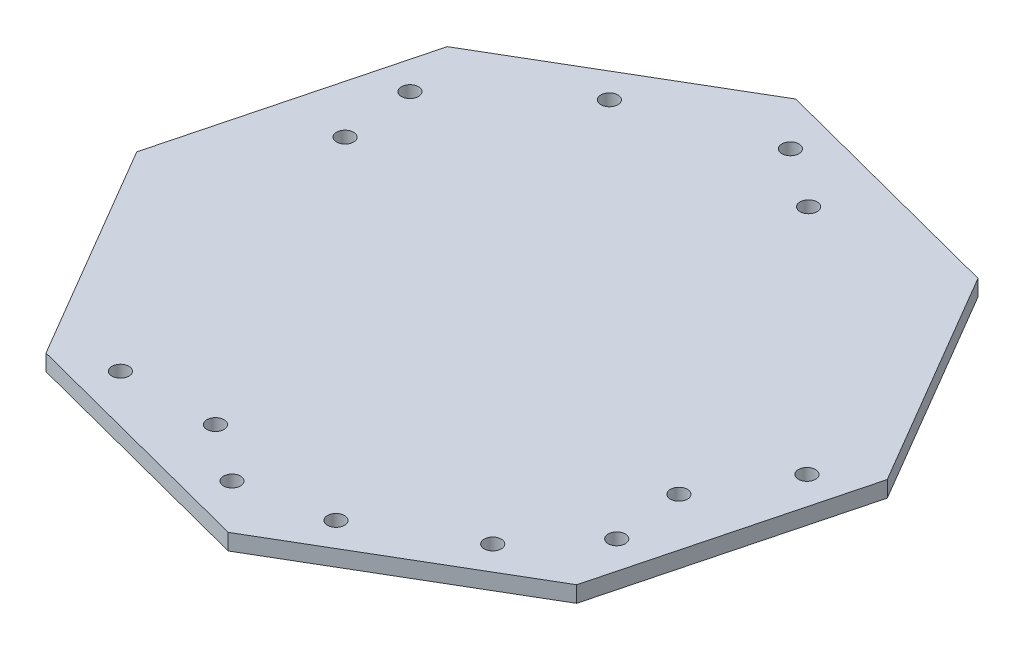
from build123d import *

# Parameters (mm, degrees)
BOSS_EXTRUDE1_DEPTH = 3
SKETCH2_R           = 1.5875
CUT_EXTRUDE1_DEPTH  = 3
SKETCH3_R           = 1.5875
CUT_EXTRUDE2_DEPTH  = 3


with BuildPart() as part:
    # Sketch1 → Boss-Extrude1 (new body)
    with BuildSketch(Plane(origin=(-113.226454214, -170.109741769, -309.439751514), x_dir=(0.890793361, 0, -0.454408614), z_dir=(0, -1, 0))):
        Polygon((16.200077076, -64.648683729), (51.592412285, -33.201987218), (54.382400165, 14.060345359), (22.935703655, 49.452680569), (-24.326628923, 52.242668449), (-59.718964132, 20.795971938), (-62.508952012, -26.466360639), (-31.062255502, -61.858695849), align=None)
    extrude(amount=BOSS_EXTRUDE1_DEPTH)

    # Sketch2 → Cut-Extrude1 (cut)
    with BuildSketch(Plane.XZ.offset(173.109741769)):
        with Locations((-145.375224309, -356.932300191)):
            Circle(SKETCH2_R)
        with Locations((-120.656222706, -365.870996639)):
            Circle(SKETCH2_R)
        with Locations((-165.234257313, -339.711726955)):
            Circle(SKETCH2_R)
        with Locations((-147.129073232, -267.776351499)):
            Circle(SKETCH2_R)
        with Locations((-119.068249233, -260.469800508)):
            Circle(SKETCH2_R)
        with Locations((-103.064133068, -263.787192741)):
            Circle(SKETCH2_R)
        with Locations((-84.693579832, -274.567395605)):
            Circle(SKETCH2_R)
        with Locations((-73.99225652, -286.921281828)):
            Circle(SKETCH2_R)
        with Locations((-66.685705529, -314.982105827)):
            Circle(SKETCH2_R)
    extrude(amount=-CUT_EXTRUDE1_DEPTH, mode=Mode.SUBTRACT)

    # Sketch3 → Cut-Extrude2 (cut)
    with BuildSketch(Plane(origin=(0, -170.109741769, 0), x_dir=(1, 0, 0), z_dir=(0, 1, 0))):
        with Locations((-163.939086588, 326.354614997)):
            Circle(SKETCH3_R)
        with Locations((-109.626964848, 358.226038945)):
            Circle(SKETCH3_R)
        with Locations((-75.39030048, 299.883308915)):
            Circle(SKETCH3_R)
        with Locations((-129.702422221, 268.011884967)):
            Circle(SKETCH3_R)
    extrude(amount=-CUT_EXTRUDE2_DEPTH, mode=Mode.SUBTRACT)


solid = part.part
